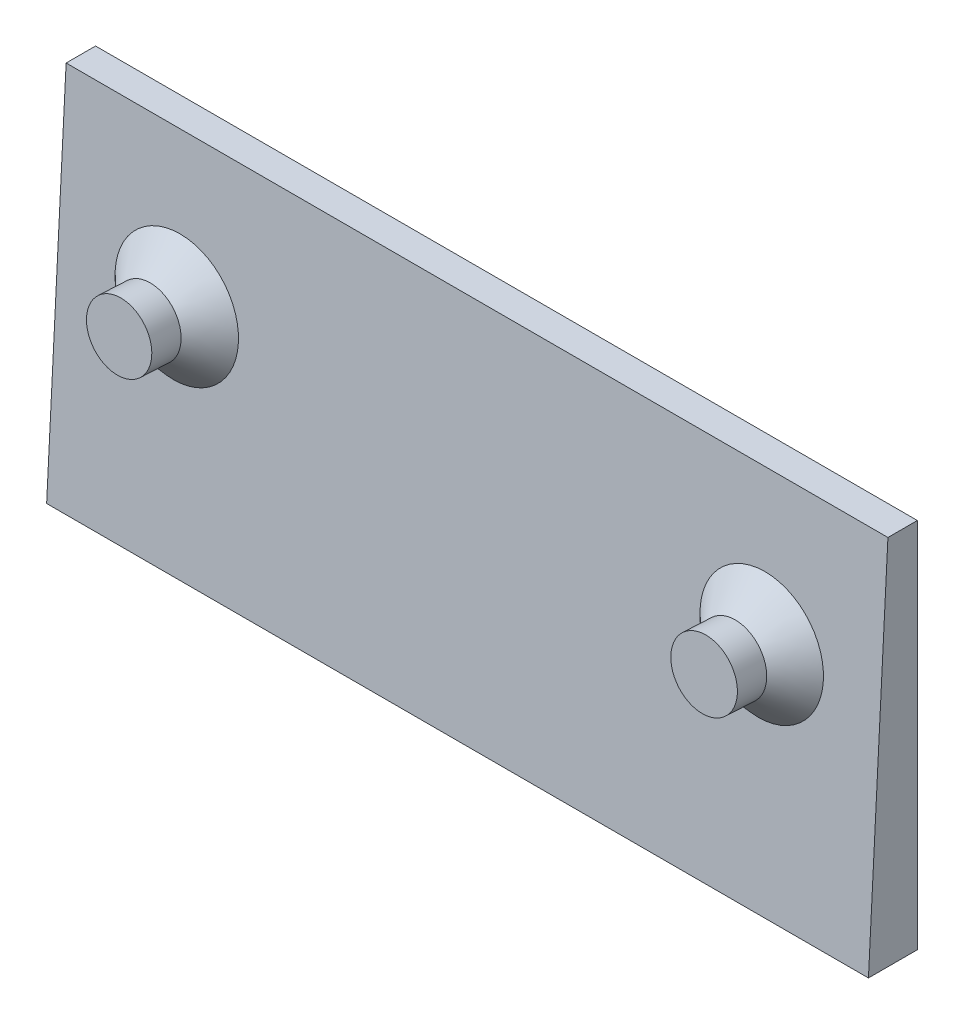
from build123d import *

# Parameters (mm, degrees)
SKETCH1_W           = 84
SKETCH1_H           = 38
BOSS_EXTRUDE1_DEPTH = 5
SKETCH2_W           = 84
SKETCH2_H           = 41.155299277
CUT_REVOLVE1_ANGLE  = 3
SKETCH3_R           = 6.3
SKETCH5_R           = 3.335164517
SKETCH3_4_R         = 6.3
SKETCH5_4_R         = 3.4
SKETCH5_8_R         = 3.335164517
SKETCH5_8_R_2       = 3.4
BOSS_EXTRUDE2_DEPTH = 3


with BuildPart() as part:
    # Sketch1 → Boss-Extrude1 (new body)
    with BuildSketch(Plane.XY):
        Rectangle(SKETCH1_W, SKETCH1_H)
    extrude(amount=BOSS_EXTRUDE1_DEPTH)

    # Sketch2 → Cut-Revolve1 (revolve, cut)
    with BuildSketch(Plane.XY.offset(5)):
        with Locations((0, 1.577649639)):
            Rectangle(SKETCH2_W, SKETCH2_H)
    revolve(axis=Axis((-42, -19, 5), (-1, 0, 0)), revolution_arc=CUT_REVOLVE1_ANGLE, mode=Mode.SUBTRACT)

    # Sketch3 → Loft2 section 0
    with BuildSketch(Plane(origin=(0, 0.209279164, 3.993284337), x_dir=(1, 0, 0), z_dir=(0, 0.052335956, 0.998629535))):
        with Locations((-29.895651858, 3.664359058)):
            Circle(SKETCH3_R)
    # Sketch5 → Loft2 section 1
    with BuildSketch(Plane(origin=(0, 0.361053437, 6.889309988), x_dir=(-1, 0, 0), z_dir=(0, -0.052335956, -0.998629535))):
        with Locations((29.895651858, 3.664359058)):
            Circle(SKETCH5_R)
    loft()

    # Sketch3_4 → Loft3 section 0
    with BuildSketch(Plane(origin=(0, 0.209279164, 3.993284337), x_dir=(1, 0, 0), z_dir=(0, 0.052335956, 0.998629535))):
        with Locations((29.895651858, 3.664359058)):
            Circle(SKETCH3_4_R)
    # Sketch5_4 → Loft3 section 1
    with BuildSketch(Plane(origin=(0, 0.361053437, 6.889309988), x_dir=(-1, 0, 0), z_dir=(0, -0.052335956, -0.998629535))):
        with Locations((-29.895651858, 3.664359058)):
            Circle(SKETCH5_4_R)
    loft()

    # Sketch5_8 → Boss-Extrude2 (add)
    with BuildSketch(Plane(origin=(0, 0.361053437, 6.889309988), x_dir=(-1, 0, 0), z_dir=(0, -0.052335956, -0.998629535))):
        with Locations((29.895651858, 3.664359058)):
            Circle(SKETCH5_8_R)
        with Locations((-29.895651858, 3.664359058)):
            Circle(SKETCH5_8_R_2)
    extrude(amount=-BOSS_EXTRUDE2_DEPTH)


solid = part.part
